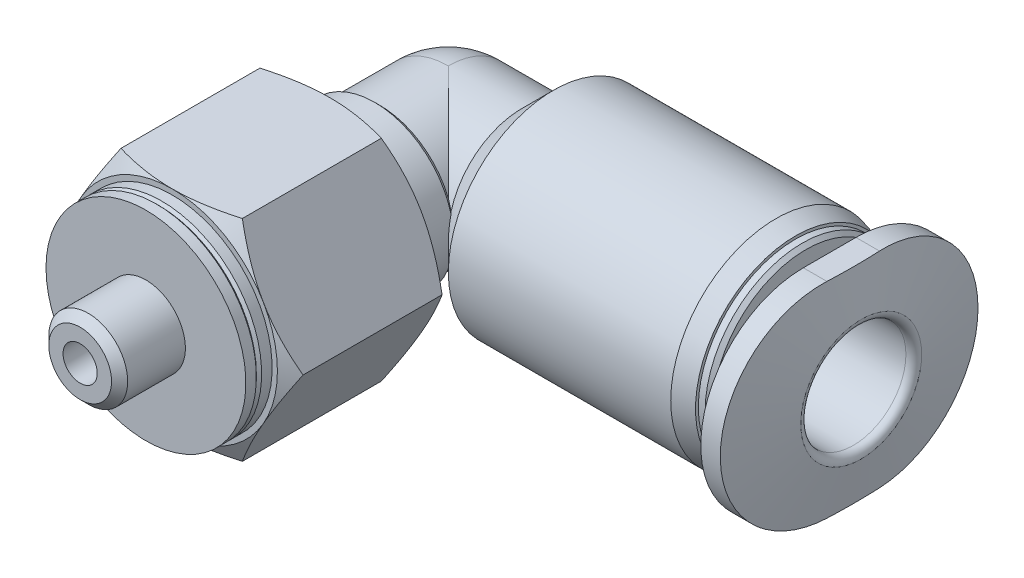
from build123d import *

# Parameters (mm, degrees)
CUT_EXTRUDE1_DEPTH = 1.2
SKETCH5_W          = 14
SKETCH5_H          = 0.65
SKETCH7_W          = 16
SKETCH7_H          = 16
CUT_EXTRUDE2_DEPTH = 7.055555556


with BuildPart() as part:
    # Sketch1 → Revolve1 (revolve)
    with BuildSketch(Plane.XY):
        with BuildLine():
            Line((0, 2.8), (2.8, 2.8))
            Line((2.8, 2.8), (4, 4))
            Line((4, 4), (12.457142857, 4))
            Line((12.457142857, 4), (13.2, 3.800952028))
            Line((13.2, 3.800952028), (13.2, 3.693772352))
            Line((13.2, 3.693772352), (13.458578644, 3.693772352))
            Line((13.458578644, 3.693772352), (13.6, 3.552350995))
            Line((13.6, 3.552350995), (13.6, 2.5))
            Line((13.6, 2.5), (14.13, 2.5))
            ThreePointArc((14.13, 2.5), (14.391629509, 2.608370491), (14.5, 2.87))
            Line((14.5, 2.87), (14.5, 5.9))
            Line((14.5, 5.9), (14.897402943, 5.9))
            ThreePointArc((14.897402943, 5.9), (15.025960465, 5.853208889), (15.094364494, 5.734729636))
            Line((15.094364494, 5.734729636), (15.7, 2.3))
            Line((15.7, 2.3), (15.7, 0))
            Line((15.7, 0), (-2.8, 0))
            ThreePointArc((-2.8, 0), (-1.979898987, 1.979898987), (0, 2.8))
        make_face()
    revolve(axis=Axis((15.7, 0, 0), (-1, 0, 0)))

    # Sketch2 → Revolve2 (revolve)
    with BuildSketch(Plane(origin=(0, 0, 0), x_dir=(0, 0, -1), z_dir=(1, 0, 0))):
        Polygon((-11.5, 0), (-11.5, 3.8), (-11.1, 3.8), (-11, 3.7), (-10.9, 3.8), (-10.5, 3.8), (-10.5, 4), (-10.130495828, 4.64), (-4.869504172, 4.64), (-4.5, 4), (-4.5, 3), (-2.8, 3), (-2.6, 2.8), (0, 2.8), (0, 0), align=None)
    revolve(axis=Axis((0, 0, 0), (0, 0, 1)))

    # Sketch3 → Revolve3 (revolve)
    with BuildSketch(Plane(origin=(0, 0, 0), x_dir=(0, 0, -1), z_dir=(1, 0, 0))):
        Polygon((-14, 0), (-14, 1.1935), (-13.6935, 1.5), (-11.5, 1.5), (-11.5, 0), align=None)
    revolve(axis=Axis((0, 0, 11.5), (0, 0, 1)))

    # Sketch4 → Cut-Extrude1 (cut)
    with BuildSketch(Plane(origin=(15.7, 0, 0), x_dir=(0, 0, -1), z_dir=(1, 0, 0))):
        Polygon((-9.8, -5.658032638), (0, -11.316065276), (9.8, -5.658032638), (9.8, 5.658032638), (0, 11.316065276), (-9.8, 5.658032638), align=None)
        with BuildLine():
            Line((-1, -3.9), (1, -3.9))
            ThreePointArc((1, -3.9), (4.9, 0), (1, 3.9))
            Line((1, 3.9), (-1, 3.9))
            ThreePointArc((-1, 3.9), (-4.9, 0), (-1, -3.9))
        make_face(mode=Mode.SUBTRACT)
    extrude(amount=-CUT_EXTRUDE1_DEPTH, mode=Mode.SUBTRACT)

    # Sketch5 → Cut-Revolve1 (revolve, cut)
    with BuildSketch(Plane(origin=(0, 0, 0), x_dir=(0, 0, -1), z_dir=(1, 0, 0))):
        with Locations((-7, 0.325)):
            Rectangle(SKETCH5_W, SKETCH5_H)
    revolve(axis=Axis((0, 0, 0), (0, 0, 1)), mode=Mode.SUBTRACT)

    # Sketch6 → Cut-Revolve2 (revolve, cut)
    with BuildSketch(Plane(origin=(0, 0, 0), x_dir=(1, 0, 0), z_dir=(0, 1, 0))):
        with BuildLine():
            Line((0, 0.65), (4.1, 0.65))
            Line((4.1, 0.65), (4.1, 2))
            Line((4.1, 2), (15.4, 2))
            ThreePointArc((15.4, 2), (15.612132034, 2.087867966), (15.7, 2.3))
            Line((15.7, 2.3), (15.7, 0))
            Line((15.7, 0), (-0.65, 0))
            ThreePointArc((-0.65, 0), (-0.459619408, 0.459619408), (0, 0.65))
        make_face()
    revolve(axis=Axis((15.7, 0, 0), (-1, 0, 0)), mode=Mode.SUBTRACT)

    # Sketch7 → Cut-Extrude2 (cut)
    with BuildSketch(Plane.XY.offset(11.5)):
        Rectangle(SKETCH7_W, SKETCH7_H)
        Polygon((-4.618802154, 0), (-2.309401077, -4), (2.309401077, -4), (4.618802154, 0), (2.309401077, 4), (-2.309401077, 4), align=None, mode=Mode.SUBTRACT)
    extrude(amount=-CUT_EXTRUDE2_DEPTH, mode=Mode.SUBTRACT)


solid = part.part
